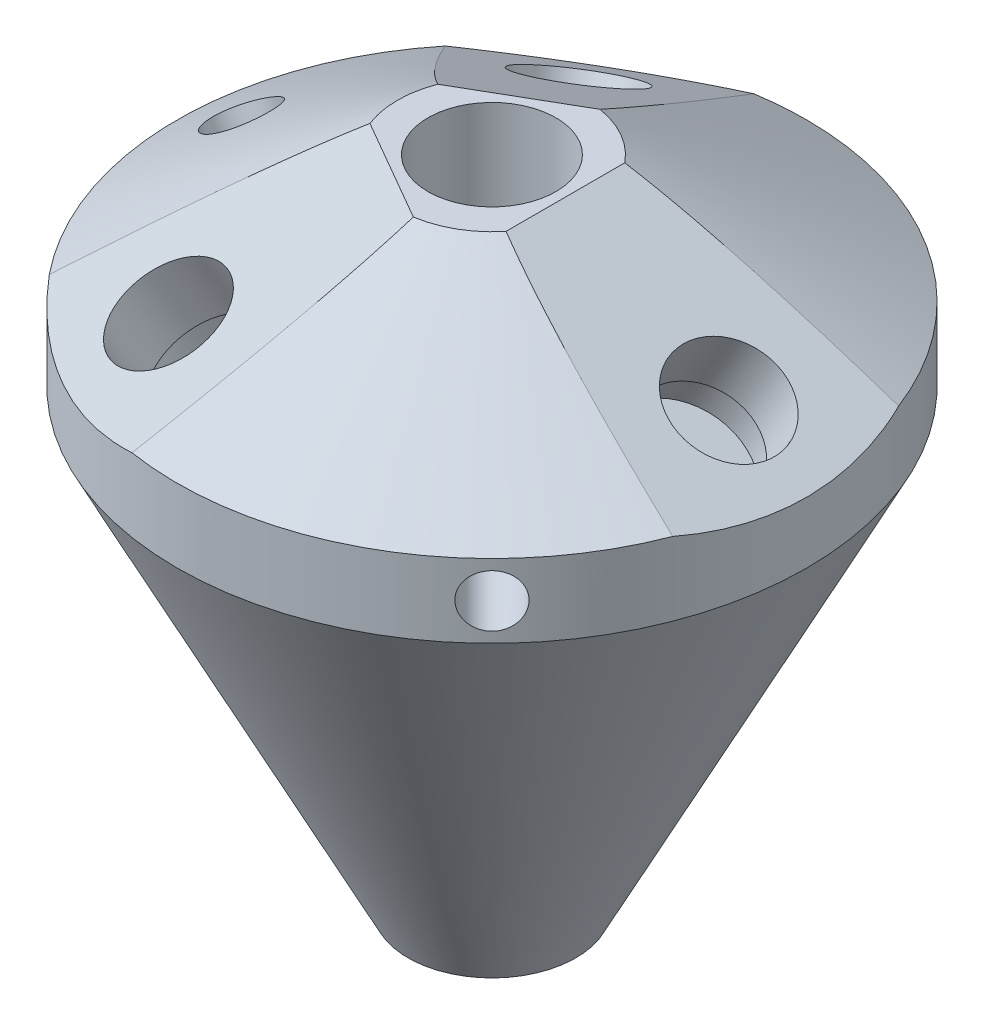
from build123d import *

# Parameters (mm, degrees)
HOLE_WIZARD_M6_1_D       = 6.1
HOLE_WIZARD_M6_1_DEPTH   = 15
HOLE_WIZARD_M6_1_TIP     = 1.832624888
SWEEP_1_PROFILE_R        = 1
SKETCH_66_W              = 50.055068194
SKETCH_66_H              = 43.519791528
CUT_EXTRUDE_4_DEPTH      = 10
HOLE_WIZARD_M6_2_D       = 5
HOLE_WIZARD_M6_2_DEPTH   = 5
PATTERN_CIRCULAR_3_COUNT = 3
SKETCH_33_R              = 1
CUT_EXTRUDE_3_DEPTH      = 8
HOLE_WIZARD_M6_3_D       = 5
HOLE_WIZARD_M6_3_DEPTH   = 6
HOLE_WIZARD_M3_1_D       = 2.5
HOLE_WIZARD_M3_1_DEPTH   = 5
HOLE_WIZARD_M3_1_TIP     = 0.751075774
HOLE_WIZARD_M3_2_D       = 2.5
HOLE_WIZARD_M3_2_DEPTH   = 15
HOLE_WIZARD_M3_2_TIP     = 0.751075774
HOLE_WIZARD_M6_3_2_D     = 3.1
HOLE_WIZARD_M6_3_2_DEPTH = 15
HOLE_WIZARD_M6_3_2_TIP   = 0.931333959
SKETCH_90_R              = 2.5
SKETCH_90_R_2            = 1
SKETCH_90_R_3            = 3
CUT_EXTRUDE_5_DEPTH      = 2
PATTERN_CIRCULAR_5_COUNT = 3
SKETCH_91_R              = 2.5
SKETCH_91_R_2            = 1
SKETCH_91_R_3            = 3
CUT_EXTRUDE_6_DEPTH      = 2


with BuildPart() as part:
    # ｽｹｯﾁ1 → 回転1 (revolve)
    with BuildSketch(Plane.XY):
        Polygon((-15, -9.562177826), (-4, -31.150893387), (0, -31.150893387), (0, 0), (-4.5, 0), (-15, -6.062177826), align=None)
    revolve(axis=Axis((0, -31.150893387, 0), (0, 1, 0)))

    # M6 すきま穴1
    with Locations(Plane(origin=(0, 0, 0), x_dir=(1, 0, 0), z_dir=(0, 1, 0))):
        with Locations((0, 0)):
            Hole(HOLE_WIZARD_M6_1_D / 2, depth=HOLE_WIZARD_M6_1_DEPTH)
            with Locations((0, 0, -(HOLE_WIZARD_M6_1_DEPTH + HOLE_WIZARD_M6_1_TIP / 2))):  # 118° drill point
                Cone(0, HOLE_WIZARD_M6_1_D / 2, HOLE_WIZARD_M6_1_TIP, mode=Mode.SUBTRACT)

    # ｶｯﾄ - ｽｲｰﾌﾟ1: sweep along a path in ｽｹｯﾁ13
    with BuildLine(Plane.XY) as sweep_1_path:
        Line((0.1, -23.869734859), (15.075399934, 2.06841869))
    # ｶｯﾄ - ｽｲｰﾌﾟ1 profile (on start of the path) → ｶｯﾄ - ｽｲｰﾌﾟ1 (sweep, cut)
    with BuildSketch(Plane(origin=(0.1, -23.869734859, 0), x_dir=(0.866025404, -0.5, 0), z_dir=(0.5, 0.866025404, 0))):
        Circle(SWEEP_1_PROFILE_R)
    sweep_1 = sweep(path=sweep_1_path.line, mode=Mode.SUBTRACT)

    # ｽｹｯﾁ66 → ｶｯﾄ - 押し出し4 (cut)
    with BuildSketch(Plane(origin=(0.875, 1.515544457, 0), x_dir=(0.866025404, -0.5, 0), z_dir=(0.5, 0.866025404, 0))):
        with Locations((12.02146997, 0)):
            Rectangle(SKETCH_66_W, SKETCH_66_H)
    cut_extrude_4 = extrude(amount=CUT_EXTRUDE_4_DEPTH, mode=Mode.SUBTRACT)

    # Hole Wizard M6 _2
    with Locations(Plane(origin=(0.875, 1.515544457, 0), x_dir=(0.866025404, -0.5, 0), z_dir=(0.5, 0.866025404, 0))):
        with Locations((12.02146997, 0)):
            hole_wizard_m6_2 = Hole(HOLE_WIZARD_M6_2_D / 2, depth=HOLE_WIZARD_M6_2_DEPTH)

    # 円形ﾊﾟﾀｰﾝ3: ｶｯﾄ - ｽｲｰﾌﾟ1, ｶｯﾄ - 押し出し4, Hole Wizard M6 _2 ×3 about axis
    pattern_circular_3_axis = Axis((0, 0, 0), (0, 1, 0))
    for i in range(1, PATTERN_CIRCULAR_3_COUNT):
        add(sweep_1.rotate(pattern_circular_3_axis, i * 360 / PATTERN_CIRCULAR_3_COUNT), mode=Mode.SUBTRACT)
        add(cut_extrude_4.rotate(pattern_circular_3_axis, i * 360 / PATTERN_CIRCULAR_3_COUNT), mode=Mode.SUBTRACT)
        add(hole_wizard_m6_2.rotate(pattern_circular_3_axis, i * 360 / PATTERN_CIRCULAR_3_COUNT), mode=Mode.SUBTRACT)

    # ｽｹｯﾁ33 → ｶｯﾄ - 押し出し3 (cut)
    with BuildSketch(Plane.XZ.offset(31.150893387)):
        Circle(SKETCH_33_R)
    extrude(amount=-CUT_EXTRUDE_3_DEPTH, mode=Mode.SUBTRACT)

    # Hole Wizard M6 _3
    with Locations(Plane.XZ.offset(31.150893387)):
        with Locations((0, 0)):
            Hole(HOLE_WIZARD_M6_3_D / 2, depth=HOLE_WIZARD_M6_3_DEPTH)

    # M3 ねじ穴1
    with Locations(Plane.ZY.offset(15)):
        with Locations((0, -7.812177826)):
            Hole(HOLE_WIZARD_M3_1_D / 2, depth=HOLE_WIZARD_M3_1_DEPTH)
            with Locations((0, 0, -(HOLE_WIZARD_M3_1_DEPTH + HOLE_WIZARD_M3_1_TIP / 2))):  # 118° drill point
                Cone(0, HOLE_WIZARD_M3_1_D / 2, HOLE_WIZARD_M3_1_TIP, mode=Mode.SUBTRACT)

    # M3 ねじ穴2
    with Locations(Plane(origin=(10.606601718, 0, 10.606601718), x_dir=(0, -1, 0), z_dir=(0.707106781, 0, 0.707106781))):
        with Locations((7.812177826, 0)):
            Hole(HOLE_WIZARD_M3_2_D / 2, depth=HOLE_WIZARD_M3_2_DEPTH)
            with Locations((0, 0, -(HOLE_WIZARD_M3_2_DEPTH + HOLE_WIZARD_M3_2_TIP / 2))):  # 118° drill point
                Cone(0, HOLE_WIZARD_M3_2_D / 2, HOLE_WIZARD_M3_2_TIP, mode=Mode.SUBTRACT)

    # Hole Wizard M6 _3 2
    with Locations(Plane(origin=(-1.125, 1.948557159, 0), x_dir=(0.866025404, 0.5, 0), z_dir=(-0.5, 0.866025404, 0))):
        with Locations((-12.5, 0)):
            Hole(HOLE_WIZARD_M6_3_2_D / 2, depth=HOLE_WIZARD_M6_3_2_DEPTH)
            with Locations((0, 0, -(HOLE_WIZARD_M6_3_2_DEPTH + HOLE_WIZARD_M6_3_2_TIP / 2))):  # 118° drill point
                Cone(0, HOLE_WIZARD_M6_3_2_D / 2, HOLE_WIZARD_M6_3_2_TIP, mode=Mode.SUBTRACT)

    # ｽｹｯﾁ90 → ｶｯﾄ - 押し出し5 (cut)
    with BuildSketch(Plane(origin=(-1.625, -2.814582562, 0), x_dir=(0.866025404, -0.5, 0), z_dir=(0.5, 0.866025404, 0))):
        with Locations((12.02146997, 0)):
            Circle(SKETCH_90_R)
        with Locations((12.02146997, 0)):
            Circle(SKETCH_90_R_2, mode=Mode.SUBTRACT)
        with Locations((12.02146997, 0)):
            Circle(SKETCH_90_R_3)
        with Locations((12.02146997, 0)):
            Circle(SKETCH_90_R, mode=Mode.SUBTRACT)
    cut_extrude_5 = extrude(amount=CUT_EXTRUDE_5_DEPTH, mode=Mode.SUBTRACT)

    # 円形ﾊﾟﾀｰﾝ5: ｶｯﾄ - 押し出し5 ×3 about axis
    pattern_circular_5_axis = Axis((0, 0, 0), (0, 1, 0))
    for i in range(1, PATTERN_CIRCULAR_5_COUNT):
        add(cut_extrude_5.rotate(pattern_circular_5_axis, i * 360 / PATTERN_CIRCULAR_5_COUNT), mode=Mode.SUBTRACT)

    # ｽｹｯﾁ91 → ｶｯﾄ - 押し出し6 (cut)
    with BuildSketch(Plane.XZ.offset(25.150893387)):
        Circle(SKETCH_91_R)
        Circle(SKETCH_91_R_2, mode=Mode.SUBTRACT)
        Circle(SKETCH_91_R_3)
        Circle(SKETCH_91_R, mode=Mode.SUBTRACT)
    extrude(amount=CUT_EXTRUDE_6_DEPTH, mode=Mode.SUBTRACT)


solid = part.part
